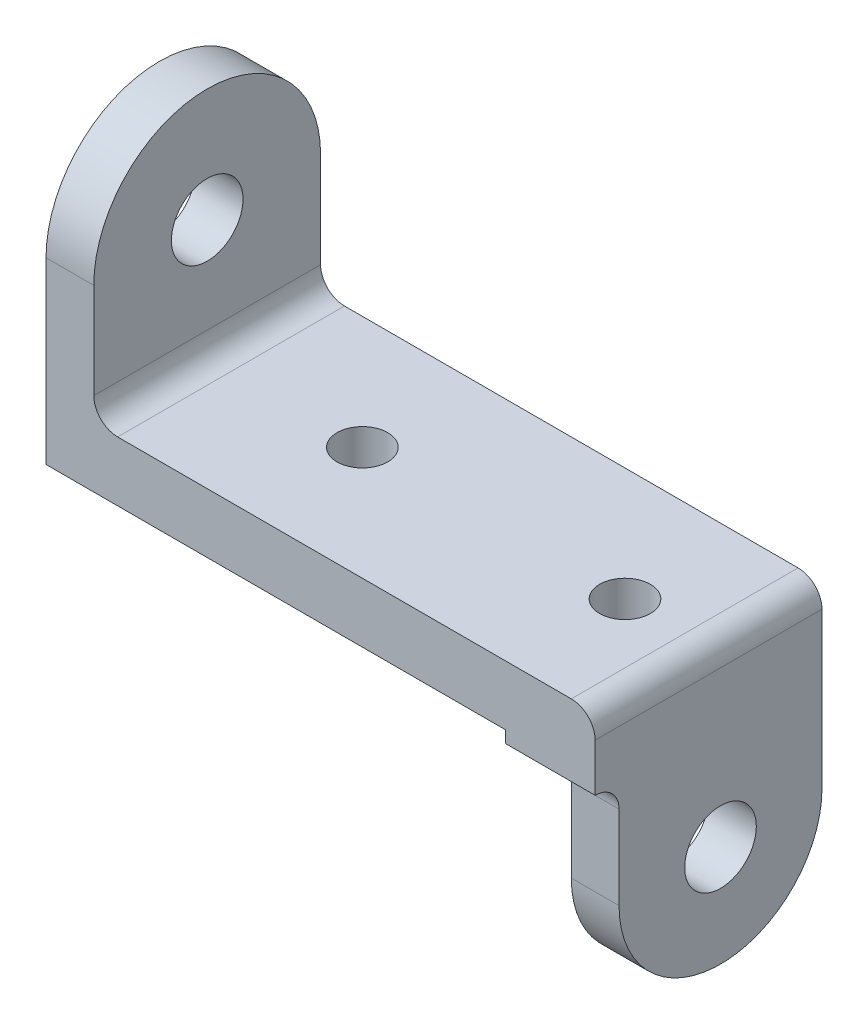
from build123d import *

# Parameters (mm, degrees)
SKETCH2_R           = 9.525
BOSS_EXTRUDE1_DEPTH = 12.7
SKETCH2_4_W         = 60.325
SKETCH2_4_H         = 15.875
BOSS_EXTRUDE2_DEPTH = 122.2375
BOSS_EXTRUDE4_START = 122.2375
BOSS_EXTRUDE4_DEPTH = 23.8125
BOSS_EXTRUDE5_START = 133.35
SKETCH2_9_R         = 9.525
BOSS_EXTRUDE5_DEPTH = 12.7
FILLET1_R           = 6.35
SKETCH3_R           = 6.746875
CUT_EXTRUDE1_DEPTH  = 175.747627398


with BuildPart() as part:
    # Sketch2 → Boss-Extrude1 (new body)
    with BuildSketch(Plane(origin=(0, 0, 0), x_dir=(0, 0, -1), z_dir=(1, 0, 0))):
        with BuildLine():
            Line((0, 0), (60.325, 0))
            Line((60.325, 0), (60.325, 47.625))
            ThreePointArc((60.325, 47.625), (30.1625, 77.7875), (0, 47.625))
            Line((0, 47.625), (0, 0))
        make_face()
        with Locations((30.1625, 47.625)):
            Circle(SKETCH2_R, mode=Mode.SUBTRACT)
    extrude(amount=BOSS_EXTRUDE1_DEPTH)

    # Sketch2_4 → Boss-Extrude2 (add)
    with BuildSketch(Plane(origin=(0, 0, 0), x_dir=(0, 0, -1), z_dir=(1, 0, 0))):
        with Locations((30.1625, 7.9375)):
            Rectangle(SKETCH2_4_W, SKETCH2_4_H)
    extrude(amount=BOSS_EXTRUDE2_DEPTH)

    # Sketch2_7 → Boss-Extrude4 (add)
    with BuildSketch(Plane(origin=(0, 0, 0), x_dir=(0, 0, -1), z_dir=(1, 0, 0)).offset(BOSS_EXTRUDE4_START)):
        with BuildLine():
            Line((60.325, -4.7625), (60.325, 15.875))
            Line((60.325, 15.875), (0, 15.875))
            Line((0, 15.875), (0, -3.175))
            ThreePointArc((0, -3.175), (2.430039796, -3.658364969), (4.490128061, -5.034871939))
            Line((4.490128061, -5.034871939), (60.325, -4.7625))
        make_face()
    extrude(amount=BOSS_EXTRUDE4_DEPTH)

    # Sketch2_9 → Boss-Extrude5 (add)
    with BuildSketch(Plane(origin=(0, 0, 0), x_dir=(0, 0, -1), z_dir=(1, 0, 0)).offset(BOSS_EXTRUDE5_START)):
        with BuildLine():
            ThreePointArc((4.490128061, -5.034871939), (5.866635031, -7.094960204), (6.35, -9.525))
            Line((6.35, -9.525), (6.35, -31.75))
            ThreePointArc((6.35, -31.75), (33.3375, -58.7375), (60.325, -31.75))
            Line((60.325, -31.75), (60.325, -4.7625))
            Line((60.325, -4.7625), (4.490128061, -5.034871939))
        make_face()
        with Locations((33.3375, -31.75)):
            Circle(SKETCH2_9_R, mode=Mode.SUBTRACT)
    extrude(amount=BOSS_EXTRUDE5_DEPTH)

    # Fillet1
    fillet1_edges = [part.edges().sort_by_distance(p)[0] for p in [
        (12.7, 15.875, -30.1625),
        (146.05, 15.875, -30.1625),
    ]]
    fillet(fillet1_edges, radius=FILLET1_R)

    # Sketch3 → Cut-Extrude1 (cut, through all)
    with BuildSketch(Plane(origin=(0, 15.875, 0), x_dir=(1, 0, 0), z_dir=(0, 1, 0))):
        with Locations((53.975, 30.1625)):
            Circle(SKETCH3_R)
        with Locations((123.825, 30.1625)):
            Circle(SKETCH3_R)
    extrude(amount=-CUT_EXTRUDE1_DEPTH, mode=Mode.SUBTRACT)


solid = part.part
